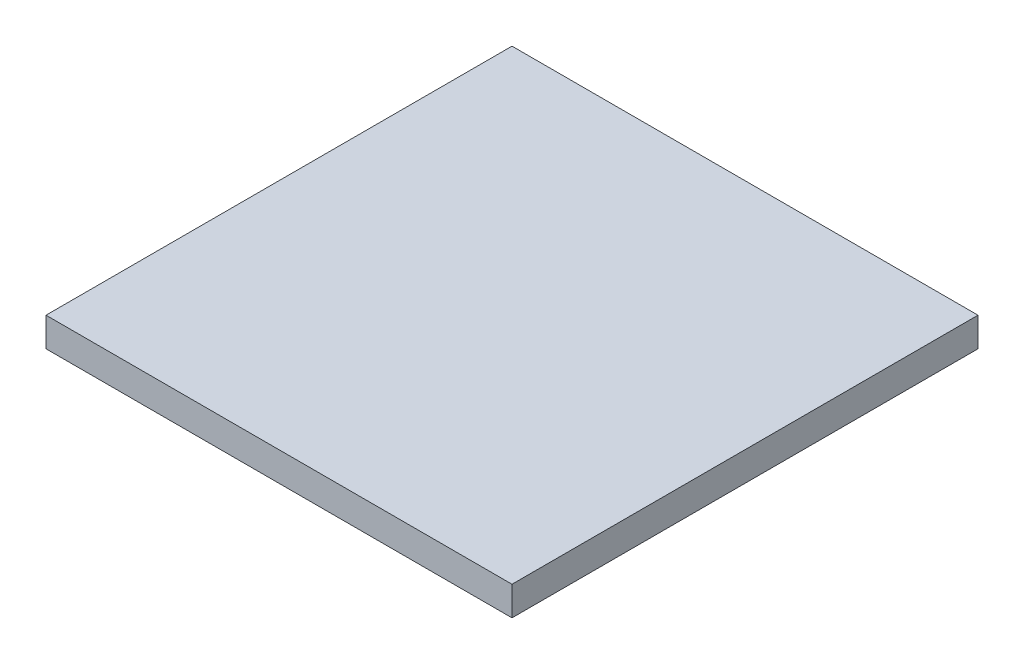
from build123d import *

# Parameters (mm, degrees)
SKETCH1_W           = 25.4
SKETCH1_H           = 25.4
BOSS_EXTRUDE1_DEPTH = 1.5875


with BuildPart() as part:
    # Sketch1 → Boss-Extrude1 (new body)
    with BuildSketch(Plane(origin=(0, 0, 0), x_dir=(1, 0, 0), z_dir=(0, 1, 0))):
        with Locations((12.7, 12.7)):
            Rectangle(SKETCH1_W, SKETCH1_H)
    extrude(amount=BOSS_EXTRUDE1_DEPTH)


solid = part.part
